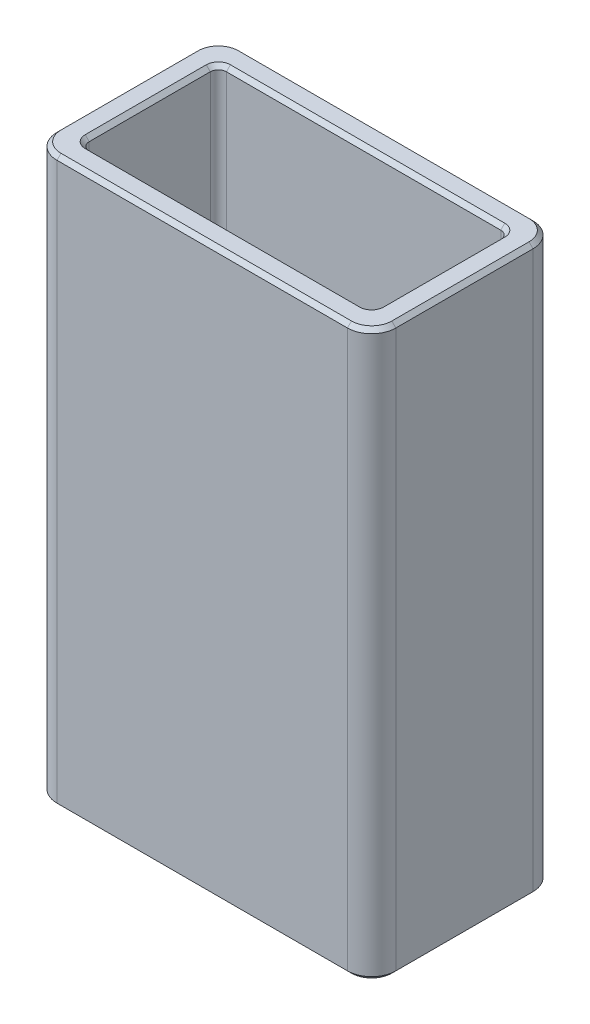
from build123d import *

# Parameters (mm, degrees)
CROQUIS1_W              = 42
CROQUIS1_H              = 23
CROQUIS1_W_2            = 36
CROQUIS1_H_2            = 17
SALIENTE_EXTRUIR1_DEPTH = 70
REDONDEO1_R             = 3
REDONDEO2_R             = 1
CHAFL_N1_SIZE           = 0.5


with BuildPart() as part:
    # Croquis1 → Saliente-Extruir1 (new body)
    with BuildSketch(Plane(origin=(0, 0, 0), x_dir=(1, 0, 0), z_dir=(0, 1, 0))):
        Rectangle(CROQUIS1_W, CROQUIS1_H)
        Rectangle(CROQUIS1_W_2, CROQUIS1_H_2, mode=Mode.SUBTRACT)
    extrude(amount=SALIENTE_EXTRUIR1_DEPTH)

    # Redondeo1
    redondeo1_edges = [part.edges().sort_by_distance(p)[0] for p in [
        (-21, 35, -11.5),
        (21, 35, -11.5),
        (21, 35, 11.5),
        (-21, 35, 11.5),
    ]]
    fillet(redondeo1_edges, radius=REDONDEO1_R)

    # Redondeo2
    redondeo2_edges = [part.edges().sort_by_distance(p)[0] for p in [
        (18, 35, 8.5),
        (18, 35, -8.5),
        (-18, 35, -8.5),
        (-18, 35, 8.5),
    ]]
    fillet(redondeo2_edges, radius=REDONDEO2_R)

    # Chaflán1
    chafl_n1_edges = [part.edges().sort_by_distance(p)[0] for p in [
        (-21, 0, 0),
        (-21, 70, 0),
        (0, 0, -11.5),
        (21, 0, 0),
        (0, 0, 11.5),
        (-20.121320344, 0, 10.621320344),
        (20.121320344, 0, 10.621320344),
        (20.121320344, 0, -10.621320344),
        (-20.121320344, 0, -10.621320344),
        (0, 70, -11.5),
        (0, 70, 11.5),
        (21, 70, 0),
        (-20.121320344, 70, 10.621320344),
        (20.121320344, 70, 10.621320344),
        (20.121320344, 70, -10.621320344),
        (-20.121320344, 70, -10.621320344),
        (0, 0, 8.5),
        (0, 70, 8.5),
        (18, 0, 0),
        (18, 70, 0),
        (0, 0, -8.5),
        (0, 70, -8.5),
        (-18, 0, 0),
        (-18, 70, 0),
        (17.707106781, 0, 8.207106781),
        (17.707106781, 70, 8.207106781),
        (17.707106781, 0, -8.207106781),
        (17.707106781, 70, -8.207106781),
        (-17.707106781, 0, -8.207106781),
        (-17.707106781, 70, -8.207106781),
        (-17.707106781, 0, 8.207106781),
        (-17.707106781, 70, 8.207106781),
    ]]
    chamfer(chafl_n1_edges, length=CHAFL_N1_SIZE)


solid = part.part
